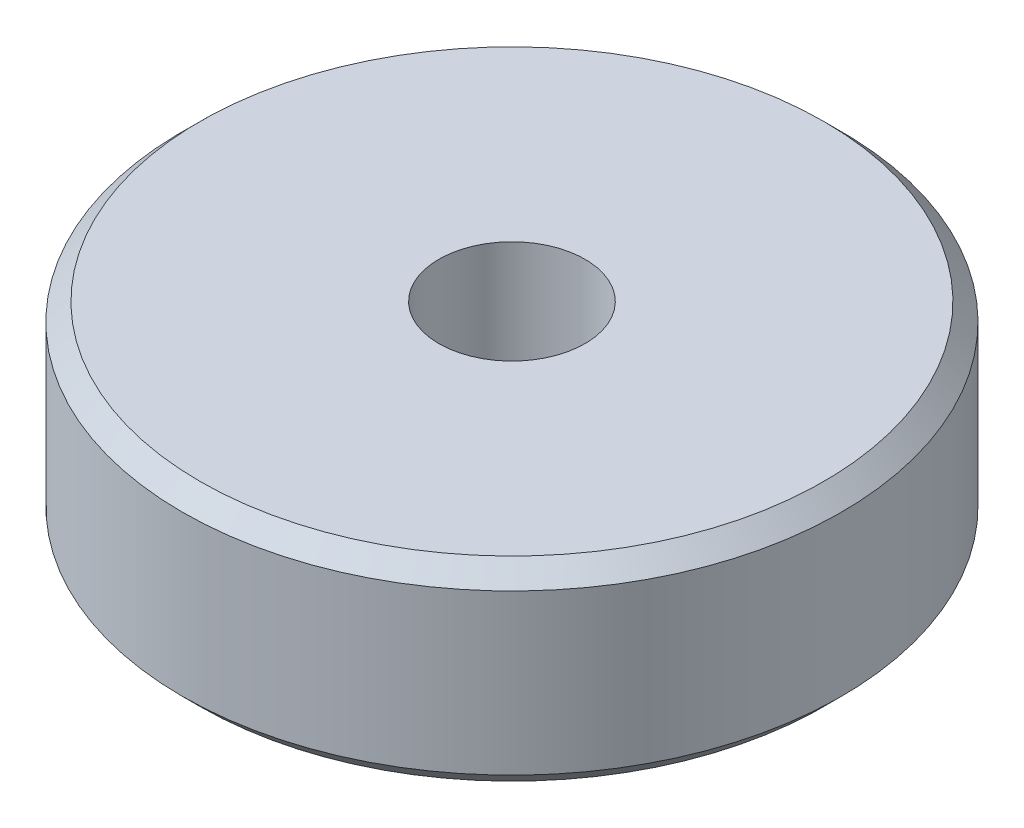
from build123d import *

# Parameters (mm, degrees)
SKETCH1_R           = 18.595
BOSS_EXTRUDE1_DEPTH = 11
SKETCH2_R           = 4.125
CUT_EXTRUDE1_DEPTH  = 12
CHAMFER1_SIZE       = 1


with BuildPart() as part:
    # Sketch1 → Boss-Extrude1 (new body)
    with BuildSketch(Plane(origin=(0, 0, 0), x_dir=(1, 0, 0), z_dir=(0, 1, 0))):
        Circle(SKETCH1_R)
    extrude(amount=BOSS_EXTRUDE1_DEPTH)

    # Sketch2 → Cut-Extrude1 (cut, through all)
    with BuildSketch(Plane(origin=(0, 11, 0), x_dir=(1, 0, 0), z_dir=(0, 1, 0))):
        Circle(SKETCH2_R)
    extrude(amount=-CUT_EXTRUDE1_DEPTH, mode=Mode.SUBTRACT)

    # Chamfer1
    chamfer1_edges = [part.edges().sort_by_distance(p)[0] for p in [
        (-18.595, 0, 0),
        (-18.595, 11, 0),
    ]]
    chamfer(chamfer1_edges, length=CHAMFER1_SIZE)


solid = part.part
